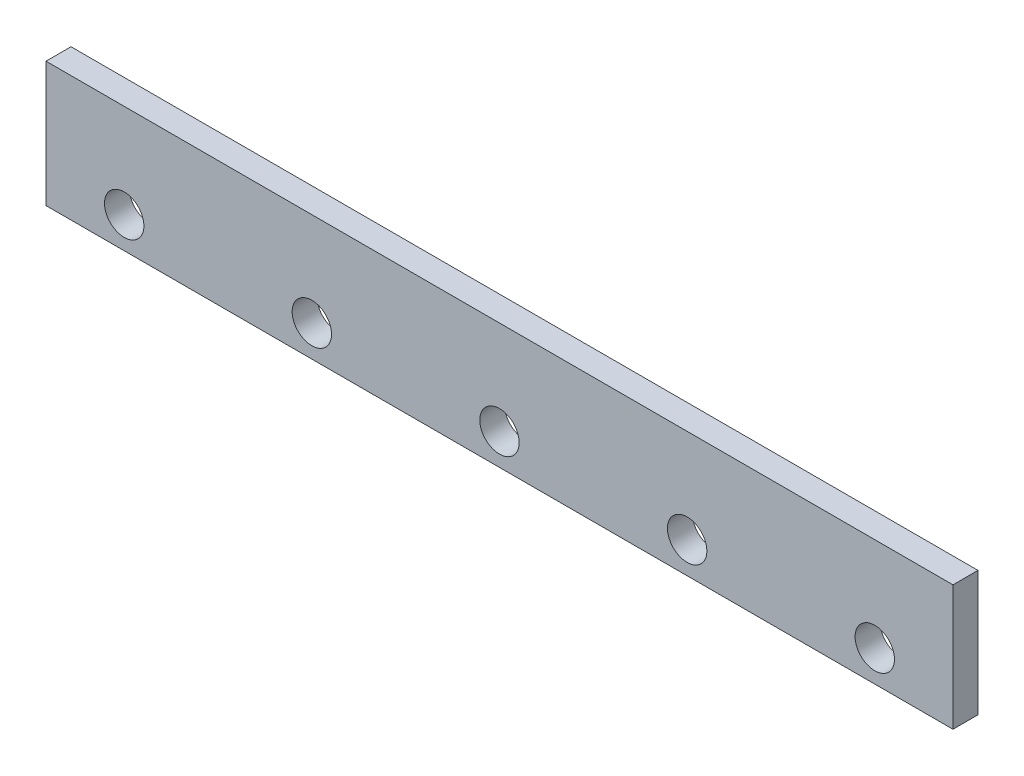
from build123d import *

# Parameters (mm, degrees)
SKETCH1_W           = 580
SKETCH1_H           = 80
SKETCH1_R           = 12.6
BOSS_EXTRUDE1_DEPTH = 16


with BuildPart() as part:
    # Sketch1 → Boss-Extrude1 (new body)
    with BuildSketch(Plane.XY):
        with Locations((290, 40)):
            Rectangle(SKETCH1_W, SKETCH1_H)
        with Locations((530, 20)):
            Circle(SKETCH1_R, mode=Mode.SUBTRACT)
        with Locations((410, 20)):
            Circle(SKETCH1_R, mode=Mode.SUBTRACT)
        with Locations((290, 20)):
            Circle(SKETCH1_R, mode=Mode.SUBTRACT)
        with Locations((170, 20)):
            Circle(SKETCH1_R, mode=Mode.SUBTRACT)
        with Locations((50, 20)):
            Circle(SKETCH1_R, mode=Mode.SUBTRACT)
    extrude(amount=BOSS_EXTRUDE1_DEPTH)


solid = part.part
